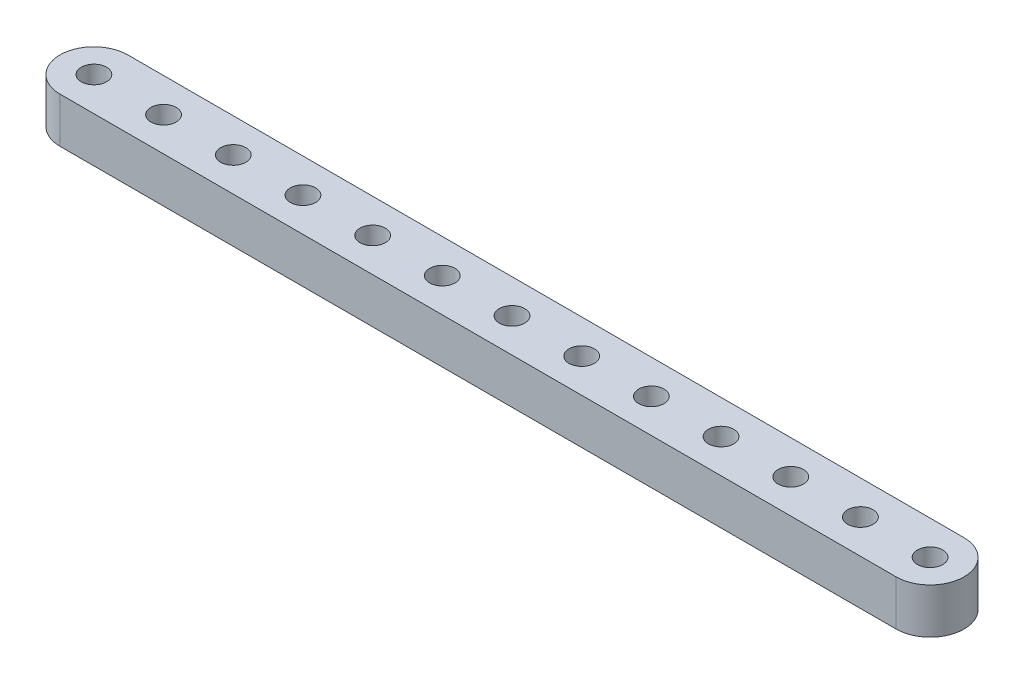
from build123d import *

# Parameters (mm, degrees)
SKETCH1_R           = 1.778
BOSS_EXTRUDE1_DEPTH = 6.35


with BuildPart() as part:
    # Sketch1 → Boss-Extrude1 (new body)
    with BuildSketch(Plane.XZ):
        with BuildLine():
            Line((-58.674, -4.7625), (58.674, -4.7625))
            ThreePointArc((58.674, -4.7625), (63.4365, 0), (58.674, 4.7625))
            Line((58.674, 4.7625), (-58.674, 4.7625))
            ThreePointArc((-58.674, 4.7625), (-63.4365, 0), (-58.674, -4.7625))
        make_face()
        with Locations((58.674, 0)):
            Circle(SKETCH1_R, mode=Mode.SUBTRACT)
        with Locations((48.895, 0)):
            Circle(SKETCH1_R, mode=Mode.SUBTRACT)
        with Locations((39.116, 0)):
            Circle(SKETCH1_R, mode=Mode.SUBTRACT)
        with Locations((29.337, 0)):
            Circle(SKETCH1_R, mode=Mode.SUBTRACT)
        with Locations((19.558, 0)):
            Circle(SKETCH1_R, mode=Mode.SUBTRACT)
        with Locations((9.779, 0)):
            Circle(SKETCH1_R, mode=Mode.SUBTRACT)
        Circle(SKETCH1_R, mode=Mode.SUBTRACT)
        with Locations((-9.779, 0)):
            Circle(SKETCH1_R, mode=Mode.SUBTRACT)
        with Locations((-19.558, 0)):
            Circle(SKETCH1_R, mode=Mode.SUBTRACT)
        with Locations((-29.337, 0)):
            Circle(SKETCH1_R, mode=Mode.SUBTRACT)
        with Locations((-39.116, 0)):
            Circle(SKETCH1_R, mode=Mode.SUBTRACT)
        with Locations((-48.895, 0)):
            Circle(SKETCH1_R, mode=Mode.SUBTRACT)
        with Locations((-58.674, 0)):
            Circle(SKETCH1_R, mode=Mode.SUBTRACT)
    extrude(amount=-BOSS_EXTRUDE1_DEPTH)


solid = part.part
